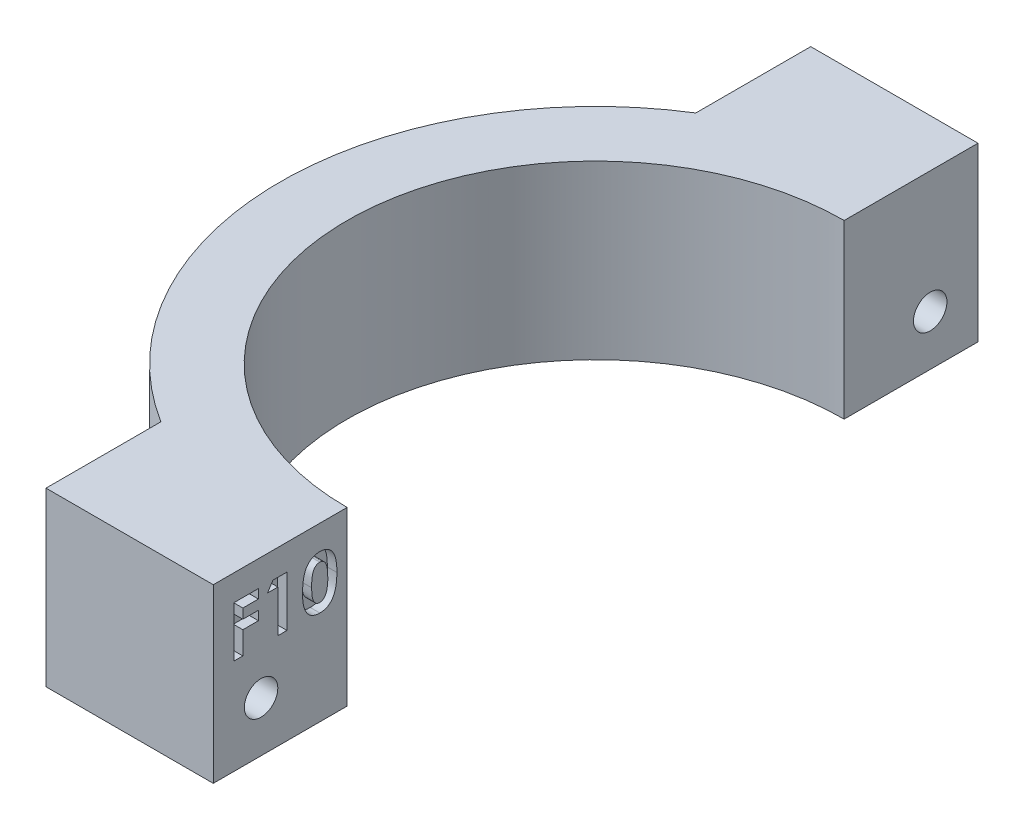
from build123d import *

# Parameters (mm, degrees)
BOSS_EXTRUDE1_DEPTH = 18
SKETCH2_R           = 1.75
CUT_EXTRUDE1_DEPTH  = 34
CUT_EXTRUDE2_DEPTH  = 1
CUT_EXTRUDE3_DEPTH  = 5


with BuildPart() as part:
    # Sketch1 → Boss-Extrude1 (new body)
    with BuildSketch(Plane(origin=(0, 0, 0), x_dir=(1, 0, 0), z_dir=(0, 1, 0))):
        with BuildLine():
            Line((-11.998275301, 32.528571429), (-29.498275301, 32.528571429))
            Line((-29.498275301, 32.528571429), (-29.498275301, 20.506241096))
            ThreePointArc((-29.498275301, 20.506241096), (-44.998275301, -7.471428571), (-29.498275301, -35.449098239))
            Line((-29.498275301, -35.449098239), (-29.498275301, -47.471428571))
            Line((-29.498275301, -47.471428571), (-11.998275301, -47.471428571))
            Line((-11.998275301, -47.471428571), (-11.998275301, -33.471428571))
            ThreePointArc((-11.998275301, -33.471428571), (-37.998275301, -7.471428571), (-11.998275301, 18.528571429))
            Line((-11.998275301, 18.528571429), (-11.998275301, 32.528571429))
        make_face()
    extrude(amount=BOSS_EXTRUDE1_DEPTH)

    # Sketch2 → Cut-Extrude1 (cut, through all)
    with BuildSketch(Plane(origin=(-11.998275301, 0, 0), x_dir=(0, 0, -1), z_dir=(1, 0, 0))):
        with Locations((-42.471428571, 5.25)):
            Circle(SKETCH2_R)
        with Locations((27.528571429, 5.25)):
            Circle(SKETCH2_R)
    extrude(amount=-CUT_EXTRUDE1_DEPTH, mode=Mode.SUBTRACT)

    # Sketch3 → Cut-Extrude2 (cut)
    with BuildSketch(Plane(origin=(-11.998275301, 0, 0), x_dir=(0, 0, -1), z_dir=(1, 0, 0))):
        Polygon((-45.326710591, 15.291960871), (-42.748719138, 15.291960871), (-42.748719138, 14.342174546), (-44.376924266, 14.342174546), (-44.376924266, 13.324546341), (-42.748719138, 13.324546341), (-42.748719138, 12.374760016), (-44.376924266, 12.374760016), (-44.376924266, 10.000294204), (-45.326710591, 10.000294204), align=None)
        Polygon((-41.231817095, 15.291960871), (-39.763676403, 15.291960871), (-39.763676403, 10.000294204), (-40.713462728, 10.000294204), (-40.713462728, 14.410016426), (-41.798932813, 14.410016426), align=None)
        with BuildLine():
            add(Edge.make_bspline(
                [(-36.353561886, 15.427644632), (-36.307588286, 15.42696214), (-36.217191905, 15.425620181), (-36.084055051, 15.411085663), (-35.955807451, 15.389128061), (-35.831947383, 15.358504863), (-35.713366407, 15.317976152), (-35.599201463, 15.269463978), (-35.490811447, 15.21042378), (-35.386814038, 15.143734844), (-35.287249296, 15.068233514), (-35.194510191, 14.9821581), (-35.106903109, 14.8874892), (-35.026324422, 14.78279559), (-34.950989689, 14.66902957), (-34.881146448, 14.546173101), (-34.817329365, 14.413624881), (-34.758823205, 14.271145717), (-34.706506811, 14.116599909), (-34.662440778, 13.948214748), (-34.624646781, 13.765951781), (-34.592745981, 13.569357327), (-34.568634132, 13.358170067), (-34.55238226, 13.132530302), (-34.541229457, 12.892873032), (-34.540319242, 12.728470114), (-34.539851616, 12.644007479)],
                knots=[0, 0, 0, 0, 0.000137869, 0.000271087, 0.000401268, 0.000528016, 0.000653387, 0.000776847, 0.000899687, 0.001023184, 0.001147212, 0.001273995, 0.001402276, 0.001533737, 0.001669859, 0.001811332, 0.001957355, 0.002110898, 0.002273142, 0.002446443, 0.002632718, 0.002831386, 0.003043736, 0.003270158, 0.003509959, 0.003763326, 0.003763326, 0.003763326, 0.003763326], degree=3))
            add(Edge.make_bspline(
                [(-34.539851616, 12.644007479), (-34.540356994, 12.558488121), (-34.541338933, 12.392325544), (-34.551918635, 12.150476247), (-34.570137381, 11.923198201), (-34.593619017, 11.710514921), (-34.625782434, 11.51253872), (-34.663450266, 11.328756974), (-34.708211869, 11.159236299), (-34.762251547, 11.004358661), (-34.820403569, 10.861629272), (-34.884395218, 10.72933949), (-34.95311113, 10.607131), (-35.024975169, 10.49316012), (-35.103927185, 10.390786655), (-35.186124362, 10.296529371), (-35.275145712, 10.213978649), (-35.36724309, 10.138880195), (-35.465790398, 10.07398006), (-35.569771342, 10.017219472), (-35.681039722, 9.971179894), (-35.797567305, 9.931137128), (-35.921340327, 9.902390743), (-36.050392052, 9.87958143), (-36.186179447, 9.866975605), (-36.278628975, 9.86541177), (-36.326001122, 9.864610443)],
                knots=[0, 0, 0, 0, 0.000256547, 0.000498466, 0.000726027, 0.000940483, 0.001140197, 0.00132751, 0.001503133, 0.001665719, 0.001819262, 0.001965285, 0.002106237, 0.002239733, 0.002369061, 0.002493713, 0.002614449, 0.002732817, 0.002849829, 0.002967931, 0.003087634, 0.003210657, 0.003337152, 0.003468377, 0.003603601, 0.003745708, 0.003745708, 0.003745708, 0.003745708], degree=3))
            add(Edge.make_bspline(
                [(-36.326001122, 9.864610443), (-36.373371991, 9.865427227), (-36.466170825, 9.867027294), (-36.602325403, 9.879487701), (-36.732061037, 9.902483144), (-36.856813303, 9.931357822), (-36.975713944, 9.971091296), (-37.089333085, 10.018508345), (-37.196797094, 10.074914775), (-37.298403521, 10.139966121), (-37.393805453, 10.214562109), (-37.484485436, 10.297904852), (-37.57024288, 10.389783097), (-37.649773202, 10.491225956), (-37.724378878, 10.600879379), (-37.793281889, 10.719995555), (-37.856440827, 10.848401053), (-37.915831314, 10.986274857), (-37.96743413, 11.136585233), (-38.01335824, 11.300674432), (-38.050978063, 11.479910274), (-38.081234442, 11.674235178), (-38.105391117, 11.883237456), (-38.123360907, 12.10701799), (-38.133999374, 12.34568101), (-38.134971016, 12.509725991), (-38.135471275, 12.594186098)],
                knots=[0, 0, 0, 0, 0.000142107, 0.000278386, 0.000409611, 0.000537137, 0.000662171, 0.000785217, 0.000906125, 0.0010258, 0.001146662, 0.001268952, 0.001394958, 0.001523261, 0.001655272, 0.00179254, 0.001935707, 0.002084361, 0.002242593, 0.002412082, 0.002595246, 0.002791652, 0.003001896, 0.003226287, 0.003465029, 0.003718396, 0.003718396, 0.003718396, 0.003718396], degree=3))
            add(Edge.make_bspline(
                [(-38.135471275, 12.594186098), (-38.134565103, 12.711536767), (-38.132816632, 12.937966394), (-38.11065873, 13.265091372), (-38.078136549, 13.567461747), (-38.03036917, 13.844571729), (-37.971305466, 14.097447652), (-37.895671318, 14.324423703), (-37.809567342, 14.528640603), (-37.736195692, 14.649619924), (-37.700859229, 14.707884682)],
                knots=[0, 0, 0, 0, 0.000351987, 0.000679164, 0.000983171, 0.00126392, 0.001522311, 0.001761317, 0.001981101, 0.002185291, 0.002185291, 0.002185291, 0.002185291], degree=3))
            add(Edge.make_bspline(
                [(-37.700859229, 14.707884682), (-37.659771672, 14.765123962), (-37.579437402, 14.877038034), (-37.438970685, 15.023960291), (-37.288057486, 15.149615399), (-37.123598134, 15.251159672), (-36.948193623, 15.331237493), (-36.760338015, 15.387795557), (-36.560725029, 15.42074892), (-36.423647462, 15.425311736), (-36.353561886, 15.427644632)],
                knots=[0, 0, 0, 0, 0.000211159, 0.000412857, 0.000607894, 0.000798799, 0.000990925, 0.001184751, 0.001385682, 0.001595891, 0.001595891, 0.001595891, 0.001595891], degree=3))
        make_face()
        with BuildLine():
            add(Edge.make_bspline(
                [(-36.33024124, 14.477858307), (-36.371801756, 14.475888421), (-36.453282428, 14.472026399), (-36.571514767, 14.439243282), (-36.68300048, 14.38860799), (-36.767804684, 14.327676333), (-36.831279787, 14.269266033), (-36.875630297, 14.216406611), (-36.918399374, 14.157419305), (-36.956175176, 14.089642323), (-36.991845394, 14.01551097), (-37.026705949, 13.934688735), (-37.055282451, 13.84519045), (-37.083358105, 13.74854028), (-37.107954999, 13.642066107), (-37.128561803, 13.524897621), (-37.146972171, 13.396272864), (-37.159813623, 13.256107588), (-37.171785709, 13.10454844), (-37.180367868, 12.941257804), (-37.183955853, 12.766279733), (-37.185096364, 12.645774932), (-37.18568495, 12.583585804)],
                knots=[0, 0, 0, 0, 0.000124476, 0.000244038, 0.000365457, 0.000490162, 0.000555412, 0.000623823, 0.000696773, 0.000773689, 0.000856181, 0.000943593, 0.001037452, 0.001137775, 0.001245513, 0.001365071, 0.001494594, 0.001635195, 0.001787227, 0.001950691, 0.002125648, 0.002312225, 0.002312225, 0.002312225, 0.002312225], degree=3))
            add(Edge.make_bspline(
                [(-37.18568495, 12.583585804), (-37.184716209, 12.503016782), (-37.182858577, 12.348519708), (-37.173129169, 12.126347537), (-37.153627378, 11.924152971), (-37.129371087, 11.740565663), (-37.095302136, 11.576776226), (-37.056103602, 11.43123506), (-37.007696898, 11.305797462), (-36.951753625, 11.198649322), (-36.88979393, 11.107498621), (-36.822533954, 11.030020115), (-36.752263661, 10.962927384), (-36.676789684, 10.908428786), (-36.596292083, 10.866663572), (-36.511442865, 10.83662237), (-36.422188108, 10.818232899), (-36.361067371, 10.81568287), (-36.33024124, 10.814396768)],
                knots=[0, 0, 0, 0, 0.000241724, 0.000463523, 0.000666886, 0.000850978, 0.001018747, 0.001168433, 0.001302685, 0.001421223, 0.001530303, 0.001632518, 0.001728508, 0.001821174, 0.001910782, 0.001999629, 0.002090477, 0.002182918, 0.002182918, 0.002182918, 0.002182918], degree=3))
            add(Edge.make_bspline(
                [(-36.33024124, 10.814396768), (-36.300472964, 10.815276815), (-36.242190381, 10.816999837), (-36.157201323, 10.834686425), (-36.07682963, 10.863440976), (-36.00131797, 10.904116306), (-35.930396249, 10.955841213), (-35.864411087, 11.018842997), (-35.803860132, 11.093749638), (-35.768582871, 11.149341444), (-35.750405169, 11.177986846)],
                knots=[0, 0, 0, 0, 8.92e-05, 0.000174643, 0.00025914, 0.000344503, 0.000431011, 0.000521735, 0.000617426, 0.00071915, 0.00071915, 0.00071915, 0.00071915], degree=3))
            add(Edge.make_bspline(
                [(-35.750405169, 11.177986846), (-35.729003986, 11.217129871), (-35.684127441, 11.299209621), (-35.632196225, 11.437716138), (-35.588483423, 11.593928598), (-35.550860453, 11.768333148), (-35.525128636, 11.961617661), (-35.502968427, 12.172556504), (-35.492280008, 12.402211879), (-35.490541478, 12.561317951), (-35.489637941, 12.644007479)],
                knots=[0, 0, 0, 0, 0.000133698, 0.000280354, 0.000442414, 0.000620174, 0.000815058, 0.001027066, 0.001256329, 0.001504413, 0.001504413, 0.001504413, 0.001504413], degree=3))
            add(Edge.make_bspline(
                [(-35.489637941, 12.644007479), (-35.489986958, 12.727414792), (-35.490658756, 12.88795963), (-35.502984298, 13.118440632), (-35.520148556, 13.328946776), (-35.545254912, 13.519008087), (-35.577558802, 13.68908595), (-35.617373468, 13.839169248), (-35.664311998, 13.969553765), (-35.719975501, 14.080109491), (-35.781626288, 14.174066693), (-35.847070481, 14.254674684), (-35.916584804, 14.323495752), (-35.990053007, 14.380788885), (-36.069175537, 14.424565135), (-36.152441049, 14.45547479), (-36.240020246, 14.474174094), (-36.299761657, 14.47661366), (-36.33024124, 14.477858307)],
                knots=[0, 0, 0, 0, 0.000250187, 0.000481568, 0.000692226, 0.000883669, 0.001056428, 0.001211224, 0.001349065, 0.001471373, 0.001581627, 0.001685596, 0.001782291, 0.00187452, 0.001964197, 0.002052409, 0.002140142, 0.002231527, 0.002231527, 0.002231527, 0.002231527], degree=3))
        make_face(mode=Mode.SUBTRACT)
    extrude(amount=-CUT_EXTRUDE2_DEPTH, mode=Mode.SUBTRACT)

    # Sketch4 → Cut-Extrude3 (cut)
    with BuildSketch(Plane.ZY.offset(29.498275301)):
        Polygon((-25.391799088, 2.901056132), (-24.425940196, 5.926027195), (-26.562712537, 8.274971063), (-29.665343769, 7.598943868), (-30.631202661, 4.573972805), (-28.49443032, 2.225028937), align=None)
        Polygon((44.716794169, 3.004634402), (45.538655018, 6.071860849), (43.293289421, 8.317226447), (40.226062974, 7.495365598), (39.404202124, 4.428139151), (41.649567722, 2.182773553), align=None)
    extrude(amount=-CUT_EXTRUDE3_DEPTH, mode=Mode.SUBTRACT)


solid = part.part
